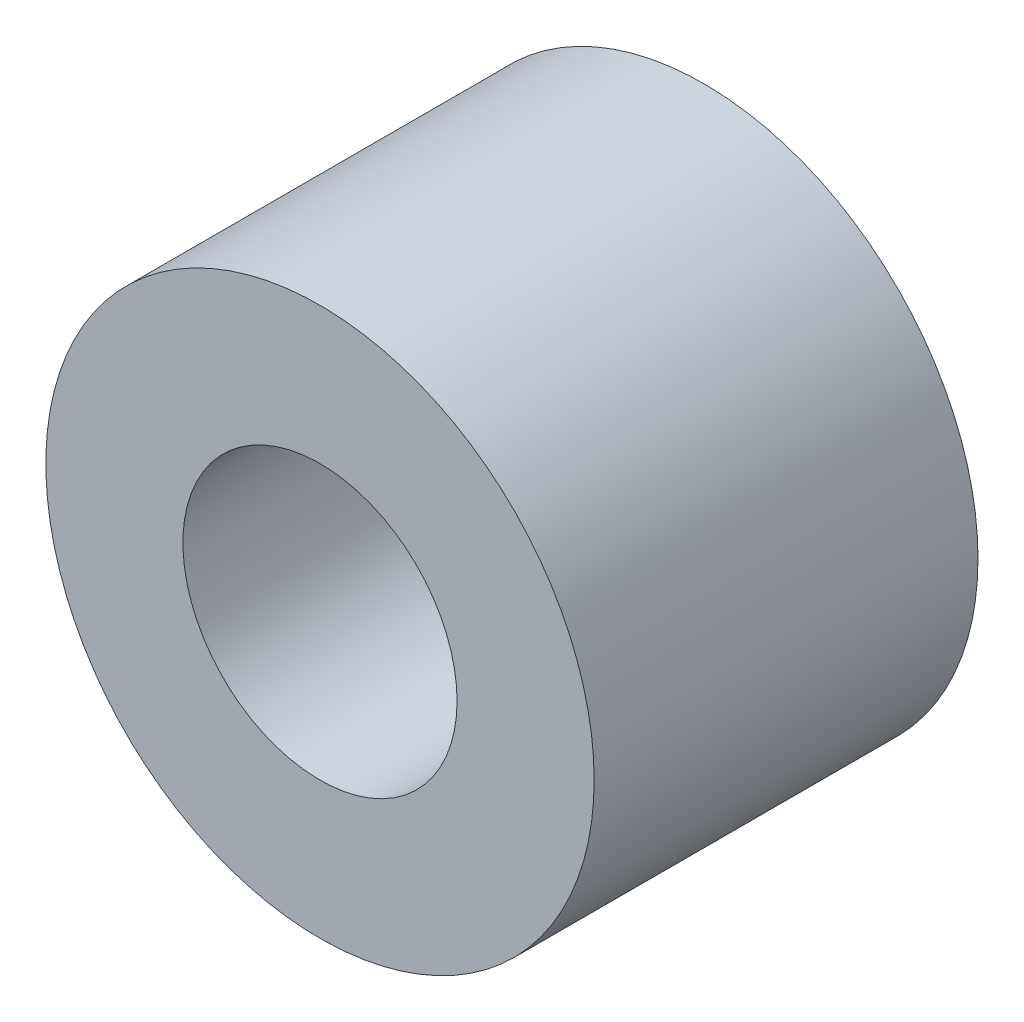
from build123d import *

# Parameters (mm, degrees)
SKETCH1_R                 = 5
BOSS_EXTRUDE1_DEPTH       = 7
F_5_0MM_DOWEL_HOLE1_D     = 5
F_5_0MM_DOWEL_HOLE1_DEPTH = 7


with BuildPart() as part:
    # Sketch1 → Boss-Extrude1 (new body)
    with BuildSketch(Plane.XY):
        Circle(SKETCH1_R)
    extrude(amount=BOSS_EXTRUDE1_DEPTH)

    # Ø5.0mm Dowel Hole1
    with Locations(Plane.XY.offset(7)):
        with Locations((0, 0)):
            Hole(F_5_0MM_DOWEL_HOLE1_D / 2, depth=F_5_0MM_DOWEL_HOLE1_DEPTH)


solid = part.part
